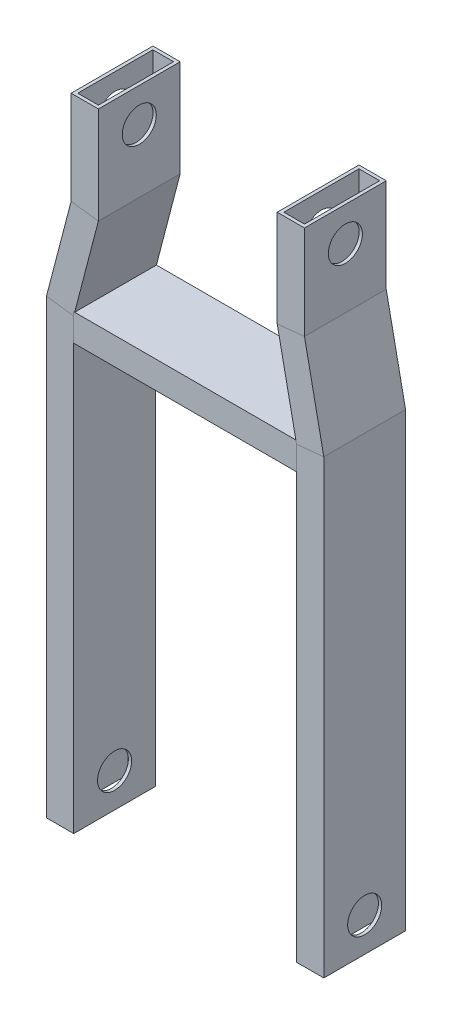
from build123d import *

# Parameters (mm, degrees)
SKETCH1_W                = 25.4
SKETCH1_H                = 76.2
SKETCH1_W_2              = 19.304
SKETCH1_H_2              = 70.104
STEEL_3X1_1_DEPTH        = 93.960760543
SKETCH1_ON_SEGMENT_2_W   = 25.4
SKETCH1_ON_SEGMENT_2_H   = 76.2
SKETCH1_ON_SEGMENT_2_W_2 = 19.304
SKETCH1_ON_SEGMENT_2_H_2 = 70.104
STEEL_3X1_1_2_DEPTH      = 100.041541103
SKETCH1_ON_SEGMENT_3_W   = 25.4
SKETCH1_ON_SEGMENT_3_H   = 76.2
SKETCH1_ON_SEGMENT_3_W_2 = 19.304
SKETCH1_ON_SEGMENT_3_H_2 = 70.104
STEEL_3X1_1_3_DEPTH      = 424.510760543
SKETCH1_ON_SEGMENT_4_W   = 25.4
SKETCH1_ON_SEGMENT_4_H   = 76.2
SKETCH1_ON_SEGMENT_4_W_2 = 19.304
SKETCH1_ON_SEGMENT_4_H_2 = 70.104
STEEL_3X1_1_4_DEPTH      = 95.055941588
SKETCH1_ON_SEGMENT_5_W   = 25.4
SKETCH1_ON_SEGMENT_5_H   = 76.2
SKETCH1_ON_SEGMENT_5_W_2 = 19.304
SKETCH1_ON_SEGMENT_5_H_2 = 70.104
STEEL_3X1_1_5_DEPTH      = 103.364670064
SKETCH1_ON_SEGMENT_6_W   = 25.4
SKETCH1_ON_SEGMENT_6_H   = 76.2
SKETCH1_ON_SEGMENT_6_W_2 = 19.304
SKETCH1_ON_SEGMENT_6_H_2 = 70.104
STEEL_3X1_1_6_DEPTH      = 425.605941588
SKETCH1_ON_SEGMENT_7_W   = 25.4
SKETCH1_ON_SEGMENT_7_H   = 76.2
SKETCH1_ON_SEGMENT_7_W_2 = 19.304
SKETCH1_ON_SEGMENT_7_H_2 = 70.104
STEEL_3X1_1_7_DEPTH      = 235.1
SKETCH3_R                = 15.875
CUT_EXTRUDE1_DEPTH       = 652.173143258
SKETCH4_R                = 15.875
CUT_EXTRUDE2_DEPTH       = 645.239445005


with BuildPart() as part:
    # Sketch1 → Steel 3X1(1) (new body)
    with BuildSketch(Plane(origin=(215.1, 596.45, 0), x_dir=(1, 0, 0), z_dir=(0, -1, 0))):
        Rectangle(SKETCH1_W, SKETCH1_H)
        Rectangle(SKETCH1_W_2, SKETCH1_H_2, mode=Mode.SUBTRACT)
    extrude(amount=STEEL_3X1_1_DEPTH)

    # Steel 3X1(1) mitre 1
    split(bisect_by=Plane(origin=(215.1, 507.55, 0), x_dir=(-0.994927025, -0.100599283, 0), z_dir=(-0.100599283, 0.994927025, 0)), keep=Keep.TOP)


with BuildPart() as body_2:
    # Sketch1 on segment 2 (carried to segment 2) → Steel 3X1_1 2 (new body)
    with BuildSketch(Plane(origin=(214.086947626, 512.508328565, 0), x_dir=(0.979759568, 0.200177891, 0), z_dir=(0.200177891, -0.979759568, 0))):
        Rectangle(SKETCH1_ON_SEGMENT_2_W, SKETCH1_ON_SEGMENT_2_H)
        Rectangle(SKETCH1_ON_SEGMENT_2_W_2, SKETCH1_ON_SEGMENT_2_H_2, mode=Mode.SUBTRACT)
    extrude(amount=STEEL_3X1_1_2_DEPTH)

    # Steel 3X1_1 2 mitre 1
    split(bisect_by=Plane(origin=(215.1, 507.55, 0), x_dir=(0.994927025, 0.100599283, 0), z_dir=(0.100599283, -0.994927025, 0)), keep=Keep.TOP)

    # Steel 3X1_1 2 mitre 2
    split(bisect_by=Plane(origin=(233.1, 419.45, 0), x_dir=(-0.994927025, -0.100599283, 0), z_dir=(-0.100599283, 0.994927025, 0)), keep=Keep.TOP)


with BuildPart() as body_3:
    # Sketch1 on segment 3 (carried to segment 3) → Steel 3X1_1 3 (new body)
    with BuildSketch(Plane(origin=(233.1, 424.510760543, 0), x_dir=(1, 0, 0), z_dir=(0, -1, 0))):
        Rectangle(SKETCH1_ON_SEGMENT_3_W, SKETCH1_ON_SEGMENT_3_H)
        Rectangle(SKETCH1_ON_SEGMENT_3_W_2, SKETCH1_ON_SEGMENT_3_H_2, mode=Mode.SUBTRACT)
    extrude(amount=STEEL_3X1_1_3_DEPTH)

    # Steel 3X1_1 3 mitre 1
    split(bisect_by=Plane(origin=(233.1, 419.45, 0), x_dir=(0.994927025, 0.100599283, 0), z_dir=(0.100599283, -0.994927025, 0)), keep=Keep.TOP)


with BuildPart() as body_4:
    # Sketch1 on segment 4 (carried to segment 4) → Steel 3X1_1 4 (new body)
    with BuildSketch(Plane(origin=(23, 596.45, 0), x_dir=(1, 0, 0), z_dir=(0, -1, 0))):
        Rectangle(SKETCH1_ON_SEGMENT_4_W, SKETCH1_ON_SEGMENT_4_H)
        Rectangle(SKETCH1_ON_SEGMENT_4_W_2, SKETCH1_ON_SEGMENT_4_H_2, mode=Mode.SUBTRACT)
    extrude(amount=STEEL_3X1_1_4_DEPTH)

    # Steel 3X1_1 4 mitre 1
    split(bisect_by=Plane(origin=(23, 507.55, 0), x_dir=(-0.991859517, 0.127336947, 0), z_dir=(0.127336947, 0.991859517, 0)), keep=Keep.TOP)


with BuildPart() as body_5:
    # Sketch1 on segment 5 (carried to segment 5) → Steel 3X1_1 5 (new body)
    with BuildSketch(Plane(origin=(24.554995309, 513.50630812, 0), x_dir=(0.967570604, -0.252600725, 0), z_dir=(-0.252600725, -0.967570604, 0))):
        Rectangle(SKETCH1_ON_SEGMENT_5_W, SKETCH1_ON_SEGMENT_5_H)
        Rectangle(SKETCH1_ON_SEGMENT_5_W_2, SKETCH1_ON_SEGMENT_5_H_2, mode=Mode.SUBTRACT)
    extrude(amount=STEEL_3X1_1_5_DEPTH)

    # Steel 3X1_1 5 mitre 1
    split(bisect_by=Plane(origin=(23, 507.55, 0), x_dir=(0.991859517, -0.127336947, 0), z_dir=(-0.127336947, -0.991859517, 0)), keep=Keep.TOP)

    # Steel 3X1_1 5 mitre 2
    split(bisect_by=Plane(origin=(0, 419.45, 0), x_dir=(-0.991859517, 0.127336947, 0), z_dir=(0.127336947, 0.991859517, 0)), keep=Keep.TOP)


with BuildPart() as body_6:
    # Sketch1 on segment 6 (carried to segment 6) → Steel 3X1_1 6 (new body)
    with BuildSketch(Plane.XZ.offset(-425.605941588)):
        Rectangle(SKETCH1_ON_SEGMENT_6_W, SKETCH1_ON_SEGMENT_6_H)
        Rectangle(SKETCH1_ON_SEGMENT_6_W_2, SKETCH1_ON_SEGMENT_6_H_2, mode=Mode.SUBTRACT)
    extrude(amount=STEEL_3X1_1_6_DEPTH)

    # Steel 3X1_1 6 mitre 1
    split(bisect_by=Plane(origin=(0, 419.45, 0), x_dir=(0.991859517, -0.127336947, 0), z_dir=(-0.127336947, -0.991859517, 0)), keep=Keep.TOP)


with BuildPart() as body_7:
    # Sketch1 on segment 7 (carried to segment 7) → Steel 3X1_1 7 (new body)
    with BuildSketch(Plane(origin=(-1, 408.59, 0), x_dir=(0, 1, 0), z_dir=(1, 0, 0))):
        Rectangle(SKETCH1_ON_SEGMENT_7_W, SKETCH1_ON_SEGMENT_7_H)
        Rectangle(SKETCH1_ON_SEGMENT_7_W_2, SKETCH1_ON_SEGMENT_7_H_2, mode=Mode.SUBTRACT)
    extrude(amount=STEEL_3X1_1_7_DEPTH)

    # Steel 3X1_1 7 mitre 1
    split(bisect_by=Plane(origin=(12.7, 408.59, 0), x_dir=(0, 1, 0), z_dir=(1, 0, 0)), keep=Keep.TOP)

    # Steel 3X1_1 7 mitre 2
    split(bisect_by=Plane(origin=(220.4, 408.59, 0), x_dir=(0, -1, 0), z_dir=(-1, 0, 0)), keep=Keep.TOP)


with BuildPart() as cut_extrude1_tool:
    # Sketch3 → Cut-Extrude1 (new, through all)
    with BuildSketch(Plane(origin=(245.8, 0, 0), x_dir=(0, 0, -1), z_dir=(1, 0, 0))):
        with Locations((0, 31.75)):
            Circle(SKETCH3_R)
    extrude(amount=-CUT_EXTRUDE1_DEPTH)


with BuildPart() as body_3_1:
    add(body_3.part)

    # Cut-Extrude1: cut by cut_extrude1_tool
    add(cut_extrude1_tool.part, mode=Mode.SUBTRACT)


with BuildPart() as body_6_1:
    add(body_6.part)

    # Cut-Extrude1: cut by cut_extrude1_tool
    add(cut_extrude1_tool.part, mode=Mode.SUBTRACT)


with BuildPart() as cut_extrude2_tool:
    # Sketch4 → Cut-Extrude2 (new, through all)
    with BuildSketch(Plane(origin=(227.8, 0, 0), x_dir=(0, 0, -1), z_dir=(1, 0, 0))):
        with Locations((0, 564.7)):
            Circle(SKETCH4_R)
    extrude(amount=-CUT_EXTRUDE2_DEPTH)


with BuildPart() as part_1:
    add(part.part)

    # Cut-Extrude2: cut by cut_extrude2_tool
    add(cut_extrude2_tool.part, mode=Mode.SUBTRACT)


with BuildPart() as body_4_1:
    add(body_4.part)

    # Cut-Extrude2: cut by cut_extrude2_tool
    add(cut_extrude2_tool.part, mode=Mode.SUBTRACT)


solid = Compound([body_2.part, body_5.part, body_7.part, body_3_1.part, body_6_1.part, part_1.part, body_4_1.part])
